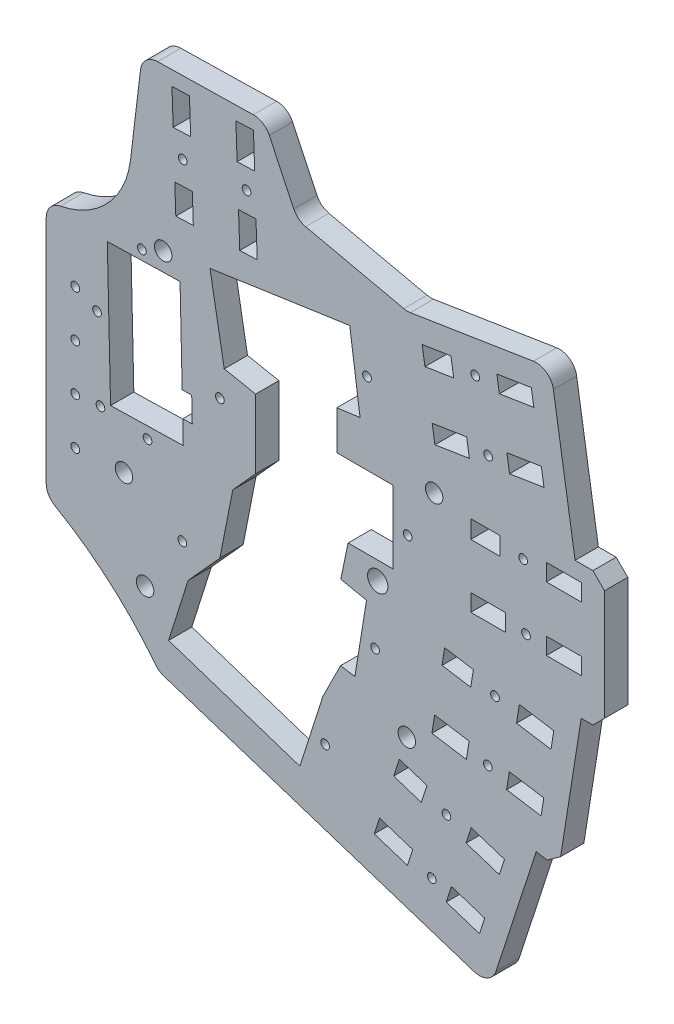
from build123d import *

# Parameters (mm, degrees)
BOSS_EXTRUDE1_DEPTH = 4
FILLET2_R           = 3
CHAMFER1_SIZE       = 2
SKETCH3_W           = 6
SKETCH3_H           = 2.945781973
SKETCH3_H_2         = 2.875060528
SKETCH3_W_2         = 5
SKETCH3_H_3         = 3.091114561
SKETCH3_H_4         = 2.916884086
CUT_EXTRUDE1_DEPTH  = 10
CUT_EXTRUDE2_DEPTH  = 5
CUT_EXTRUDE3_DEPTH  = 5
CUT_EXTRUDE4_DEPTH  = 5
SKETCH7_R           = 0.75
CUT_EXTRUDE5_DEPTH  = 5
SKETCH8_R           = 0.75
CUT_EXTRUDE6_DEPTH  = 5
SKETCH9_R           = 0.75
CUT_EXTRUDE7_DEPTH  = 5
SKETCH10_R          = 0.75
CUT_EXTRUDE8_DEPTH  = 5
SKETCH11_R          = 0.75
CUT_EXTRUDE9_DEPTH  = 5
CUT_EXTRUDE10_DEPTH = 5
SKETCH13_R          = 0.75
CUT_EXTRUDE11_DEPTH = 5
SKETCH14_R          = 1.5
SKETCH14_R_2        = 1.75
CUT_EXTRUDE12_DEPTH = 5
SKETCH15_R          = 1.5
CUT_EXTRUDE13_DEPTH = 5


with BuildPart() as part:
    # Sketch1 → Boss-Extrude1 (new body)
    with BuildSketch(Plane.XY):
        with BuildLine():
            Line((-82.5, 0), (-82.5, -22))
            ThreePointArc((-82.5, -22), (-71.937482469, -29.234295618), (-63.150209187, -38.544807848))
            Line((-63.150209187, -38.544807848), (-6.08681821, -57.08582751))
            Line((-6.08681821, -57.08582751), (1.750023953, -32.966507402))
            Line((1.750023953, -32.966507402), (5.635516857, -33.581909022))
            Line((5.635516857, -33.581909022), (9.491743582, -9.234651698))
            Line((9.491743582, -9.234651698), (13.5, -9.234651698))
            Line((13.5, -9.234651698), (13.5, 13.765348302))
            Line((13.5, 13.765348302), (8.439930603, 13.765348302))
            Line((8.439930603, 13.765348302), (4.236597169, 40.304151133))
            Line((4.236597169, 40.304151133), (-20.455611345, 36.393289507))
            Line((-20.455611345, 36.393289507), (-39.3127261, 40.602575288))
            Line((-39.3127261, 40.602575288), (-44.967288116, 52.493297823))
            Line((-44.967288116, 52.493297823), (-60.967288116, 52.177474986))
            Line((-60.967288116, 52.177474986), (-65.967288116, 52.07878035))
            Line((-65.967288116, 52.07878035), (-68.000538667, 35.200809731))
            ThreePointArc((-68.000538667, 35.200809731), (-72.794617154, 25.903173821), (-82.5, 22))
            Line((-82.5, 22), (-82.5, 0))
        make_face()
    extrude(amount=-BOSS_EXTRUDE1_DEPTH)

    # Fillet2
    fillet2_edges = [part.edges().sort_by_distance(p)[0] for p in [
        (-63.150209187, -38.544807848, -2),
        (-82.5, -22, -2),
        (-82.5, 22, -2),
        (-65.967288116, 52.07878035, -2),
        (-44.967288116, 52.493297823, -2),
        (-39.3127261, 40.602575288, -2),
        (-20.455611345, 36.393289507, -2),
        (4.236597169, 40.304151133, -2),
        (-6.08681821, -57.08582751, -2),
    ]]
    fillet(fillet2_edges, radius=FILLET2_R)

    # Chamfer1
    chamfer1_edges = [part.edges().sort_by_distance(p)[0] for p in [
        (13.5, 13.765348302, -2),
        (13.5, -9.234651698, -2),
        (5.635516857, -33.581909022, -2),
    ]]
    chamfer(chamfer1_edges, length=CHAMFER1_SIZE)

    # Sketch3 → Cut-Extrude1 (cut)
    with BuildSketch(Plane(origin=(0, 0, -4), x_dir=(-1, 0, 0), z_dir=(0, 0, -1))):
        Polygon((12.816230423, -45.43614892), (7.109891326, -47.290250886), (8.008966048, -50.057318359), (13.715305146, -48.203216392), align=None)
        Polygon((25.179965135, -41.418927993), (19.473626037, -43.273029959), (20.386714833, -46.083228314), (26.093053931, -44.229126348), align=None)
        Polygon((21.780778197, -30.957306314), (17.025495616, -32.502391286), (17.999387351, -35.499721846), (22.754669932, -33.954636874), align=None)
        Polygon((9.417043485, -34.974527241), (3.710704387, -36.828629207), (4.597788177, -39.558792383), (10.304127275, -37.704690417), align=None)
        Polygon((15.710112404, -21.326484006), (9.78398236, -22.265090796), (10.255269922, -25.240683357), (16.181399966, -24.302076567), align=None)
        Polygon((2.870163976, -23.360132052), (-3.055966068, -24.298738842), (-2.593703912, -27.217347226), (3.332426131, -26.278740436), align=None)
        Polygon((13.989333288, -10.461912259), (9.050891585, -11.244084585), (9.503179715, -14.099719447), (14.441621418, -13.317547122), align=None)
        Polygon((1.14938486, -12.495560305), (-4.776745183, -13.434167095), (-4.297884586, -16.457573915), (1.628245458, -15.518967125), align=None)
        with Locations((6.5, -1.472890987)):
            Rectangle(SKETCH3_W, SKETCH3_H)
        with Locations((-6.5, -1.437530264)):
            Rectangle(SKETCH3_W, SKETCH3_H_2)
        with Locations((7, 9.45444272)):
            Rectangle(SKETCH3_W_2, SKETCH3_H_3)
        with Locations((-6.5, 9.541557957)):
            Rectangle(SKETCH3_W, SKETCH3_H_4)
        Polygon((16.133717689, 21.890833328), (10.207587645, 22.829440118), (9.73678448, 19.856905919), (15.662914523, 18.918299128), align=None)
        Polygon((3.293769261, 23.924481374), (-2.632360783, 24.863088164), (-3.093591966, 21.950989081), (2.832538078, 21.012382291), align=None)
        Polygon((17.854496804, 32.755405075), (12.916055101, 33.5375774), (12.431880363, 30.480618416), (17.370322066, 29.698446091), align=None)
        Polygon((5.014548376, 34.78905312), (-0.911581667, 35.72765991), (-1.344812636, 32.992347222), (4.581317407, 32.053740432), align=None)
    extrude(amount=-CUT_EXTRUDE1_DEPTH, mode=Mode.SUBTRACT)

    # Sketch4 → Cut-Extrude2 (cut, through all)
    with BuildSketch(Plane(origin=(0, 0, -4), x_dir=(-1, 0, 0), z_dir=(0, 0, -1))):
        Polygon((61.461861486, -33.112780309), (38.875160748, -40.557320866), (34.941208429, -28.205556594), (31.890475236, -22.08234188), (29.422452502, -22.48091908), (27.425228716, -10.113945501), (31.846007079, -9.19781647), (30.596587071, -3.168743327), (22.846023992, -3.168743327), (22.846023992, 9.3), (32.534265366, 9.3), (32.534265366, 15.998319193), (28.533481358, 16.537502585), (30.310955757, 29.359979981), (54.335741925, 25.84189954), (51.886829877, 12.115657968), (46.495560397, 11.056658606), (46.495560397, -0.8192261), (50.419003961, -5.159962771), (52.634709942, -16.439920489), (58.094962161, -22.48091908), align=None)
    extrude(amount=-CUT_EXTRUDE2_DEPTH, mode=Mode.SUBTRACT)

    # Sketch5 → Cut-Extrude3 (cut, through all)
    with BuildSketch(Plane.XY):
        Polygon((-71.99443726, 21.028931398), (-71.435141734, -3.122466307), (-58.930433709, -2.832883595), (-59.489729235, 21.31851411), align=None)
    extrude(amount=-CUT_EXTRUDE3_DEPTH, mode=Mode.SUBTRACT)

    # Sketch6 → Cut-Extrude4 (cut, through all)
    with BuildSketch(Plane.XY):
        Polygon((-60.670642394, 43.682652957), (-60.880039374, 49.678997919), (-57.870330417, 49.784099271), (-57.660933437, 43.787754309), align=None)
        Polygon((-60.216948937, 30.690572205), (-60.39144642, 35.68752634), (-57.377728432, 35.792767692), (-57.203230948, 30.795813557), align=None)
        Polygon((-49.223649839, 31.074466669), (-49.43304682, 37.070811631), (-46.432764223, 37.175583808), (-46.223367243, 31.179238846), align=None)
        Polygon((-49.677343296, 44.06654742), (-49.886740277, 50.062892382), (-46.866153794, 50.168373587), (-46.656756814, 44.172028625), align=None)
    extrude(amount=-CUT_EXTRUDE4_DEPTH, mode=Mode.SUBTRACT)

    # Sketch7 → Cut-Extrude5 (cut, through all)
    with BuildSketch(Plane.XY):
        with Locations((-59.025187671, 39.737675325)):
            Circle(SKETCH7_R)
        with Locations((-48.049977788, 40.621242871)):
            Circle(SKETCH7_R)
        with Locations((-8.735950312, 32.715247342)):
            Circle(SKETCH7_R)
        with Locations((-6.517669866, 21.905802425)):
            Circle(SKETCH7_R)
        with Locations((-0.5, 9.498000338)):
            Circle(SKETCH7_R)
        with Locations((0, -1.455210625)):
            Circle(SKETCH7_R)
        with Locations((-5.332925404, -13.339582866)):
            Circle(SKETCH7_R)
        with Locations((-6.560460597, -24.28616166)):
            Circle(SKETCH7_R)
        with Locations((-13.686513432, -35.170332697)):
            Circle(SKETCH7_R)
        with Locations((-16.205863174, -45.874906063)):
            Circle(SKETCH7_R)
    extrude(amount=-CUT_EXTRUDE5_DEPTH, mode=Mode.SUBTRACT)

    # Sketch8 → Cut-Extrude6 (cut, through all)
    with BuildSketch(Plane(origin=(0, 0, -4), x_dir=(-1, 0, 0), z_dir=(0, 0, -1))):
        with Locations((65.076045823, -4.950719542)):
            Circle(SKETCH8_R)
        with Locations((66.046251832, 22.832345449)):
            Circle(SKETCH8_R)
    extrude(amount=-CUT_EXTRUDE6_DEPTH, mode=Mode.SUBTRACT)

    # Sketch9 → Cut-Extrude7 (cut, through all)
    with BuildSketch(Plane.XY):
        with Locations((-27.335083026, 23.255353238)):
            Circle(SKETCH9_R)
        with Locations((-20.35, 3.1)):
            Circle(SKETCH9_R)
        with Locations((-25.941584057, -16.567336204)):
            Circle(SKETCH9_R)
        with Locations((-34.540975654, -35.117818403)):
            Circle(SKETCH9_R)
    extrude(amount=-CUT_EXTRUDE7_DEPTH, mode=Mode.SUBTRACT)

    # Sketch10 → Cut-Extrude8 (cut, through all)
    with BuildSketch(Plane.XY):
        with Locations((-77.5, 3.5403043)):
            Circle(SKETCH10_R)
        with Locations((-77.5, 11.5403043)):
            Circle(SKETCH10_R)
        with Locations((-77.5, -4.4596957)):
            Circle(SKETCH10_R)
        with Locations((-77.5, -12.4596957)):
            Circle(SKETCH10_R)
    extrude(amount=-CUT_EXTRUDE8_DEPTH, mode=Mode.SUBTRACT)

    # Sketch11 → Cut-Extrude9 (cut)
    with BuildSketch(Plane(origin=(0, 0, -4), x_dir=(-1, 0, 0), z_dir=(0, 0, -1))):
        with Locations((73.176178498, -4.091448782)):
            Circle(SKETCH11_R)
        with Locations((73.756130882, 9.746257553)):
            Circle(SKETCH11_R)
    extrude(amount=-CUT_EXTRUDE9_DEPTH, mode=Mode.SUBTRACT)

    # Sketch12 → Cut-Extrude10 (cut)
    with BuildSketch(Plane.XY):
        Polygon((-59.021835668, 1.114019176), (-59.120578238, 5.377902889), (-57.483855438, 5.415805943), (-57.385112867, 1.15192223), align=None)
    extrude(amount=-CUT_EXTRUDE10_DEPTH, mode=Mode.SUBTRACT)

    # Sketch13 → Cut-Extrude11 (cut)
    with BuildSketch(Plane.XY):
        with Locations((-59.090495064, -17.158775628)):
            Circle(SKETCH13_R)
        with Locations((-52.634709942, 7.375968546)):
            Circle(SKETCH13_R)
    extrude(amount=-CUT_EXTRUDE11_DEPTH, mode=Mode.SUBTRACT)

    # Sketch14 → Cut-Extrude12 (cut)
    with BuildSketch(Plane(origin=(0, 0, -4), x_dir=(-1, 0, 0), z_dir=(0, 0, -1))):
        with Locations((69.134619845, -11.952007531)):
            Circle(SKETCH14_R)
        with Locations((25.5, -6.29339012)):
            Circle(SKETCH14_R_2)
        with Locations((62.382012848, 24.426589181)):
            Circle(SKETCH14_R)
    extrude(amount=-CUT_EXTRUDE12_DEPTH, mode=Mode.SUBTRACT)

    # Sketch15 → Cut-Extrude13 (cut, through all)
    with BuildSketch(Plane(origin=(0, 0, -4), x_dir=(-1, 0, 0), z_dir=(0, 0, -1))):
        with Locations((65.5, -27.039327647)):
            Circle(SKETCH15_R)
        with Locations((20.5, -27.039327647)):
            Circle(SKETCH15_R)
        with Locations((15.8, 11.676431418)):
            Circle(SKETCH15_R)
    extrude(amount=-CUT_EXTRUDE13_DEPTH, mode=Mode.SUBTRACT)


solid = part.part
